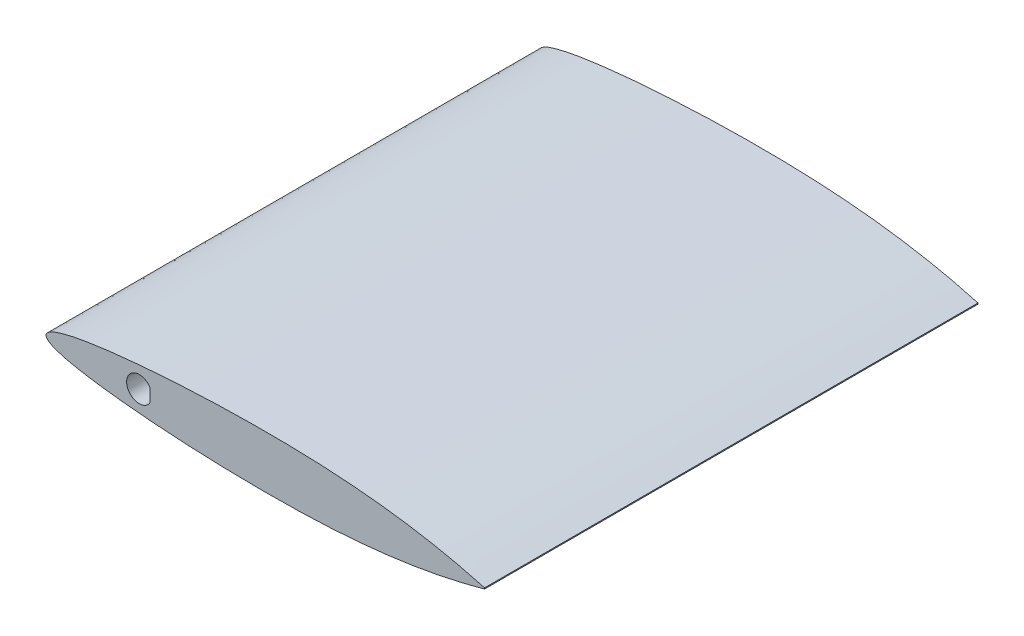
from build123d import *

# Parameters (mm, degrees)
BOSS_EXTRUDE1_DEPTH = 114.3
CUT_EXTRUDE1_DEPTH  = 115.3000001


with BuildPart() as part:
    # Sketch1 → Boss-Extrude1 (new body)
    with BuildSketch(Plane.XY):
        with BuildLine():
            Line((101.6, 0.12192), (101.6, -0.12192))
            add(Edge.make_bspline(
                [(101.6, 0.12192), (99.909932561, 0.573751352), (96.544515968, 1.473479194), (89.783814833, 2.947081601), (81.321913594, 4.36676175), (71.140279871, 5.436356516), (60.967102616, 5.996645411), (50.800006263, 6.145246679), (40.635675917, 5.998253513), (30.470830523, 5.552954054), (22.003048387, 4.932932422), (15.230811891, 4.223162727), (10.998681463, 3.664214628), (7.608030333, 3.092241666), (5.072149413, 2.580804534), (2.89436287, 1.970888591), (1.181665174, 1.364209186), (-0.674617494, 0), (1.181665174, -1.364209186), (2.89436287, -1.970888591), (5.072149413, -2.580804534), (7.608030333, -3.092241666), (10.998681463, -3.664214628), (15.230811891, -4.223162727), (22.003048387, -4.932932422), (30.470830523, -5.552954054), (40.635675917, -5.998253513), (50.800006263, -6.145246679), (60.967102616, -5.996645411), (71.140279871, -5.436356516), (81.321913594, -4.36676175), (89.783814833, -2.947081601), (96.544515968, -1.473479194), (99.909932561, -0.573751352), (101.6, -0.12192)],
                knots=[0, 0, 0, 0, 0.025456141, 0.050690592, 0.100668945, 0.150236314, 0.199601231, 0.248893973, 0.298185188, 0.347518476, 0.39694404, 0.421724596, 0.446593141, 0.459091427, 0.471679672, 0.4844804, 0.491139797, 0.5, 0.508860203, 0.5155196, 0.528320328, 0.540908573, 0.553406859, 0.578275404, 0.60305596, 0.652481524, 0.701814812, 0.751106027, 0.800398769, 0.849763686, 0.899331055, 0.949309408, 0.974543859, 1, 1, 1, 1], degree=3))
        make_face()
    extrude(amount=BOSS_EXTRUDE1_DEPTH)

    # Sketch2 → Cut-Extrude1 (cut, through all)
    with BuildSketch(Plane.XY.offset(114.3)):
        with BuildLine():
            Line((24.056719103, 1.5875), (24.056719103, -1.5875))
            ThreePointArc((24.056719103, -1.5875), (18.675, 0), (24.056719103, 1.5875))
        make_face()
    extrude(amount=-CUT_EXTRUDE1_DEPTH, mode=Mode.SUBTRACT)


solid = part.part
